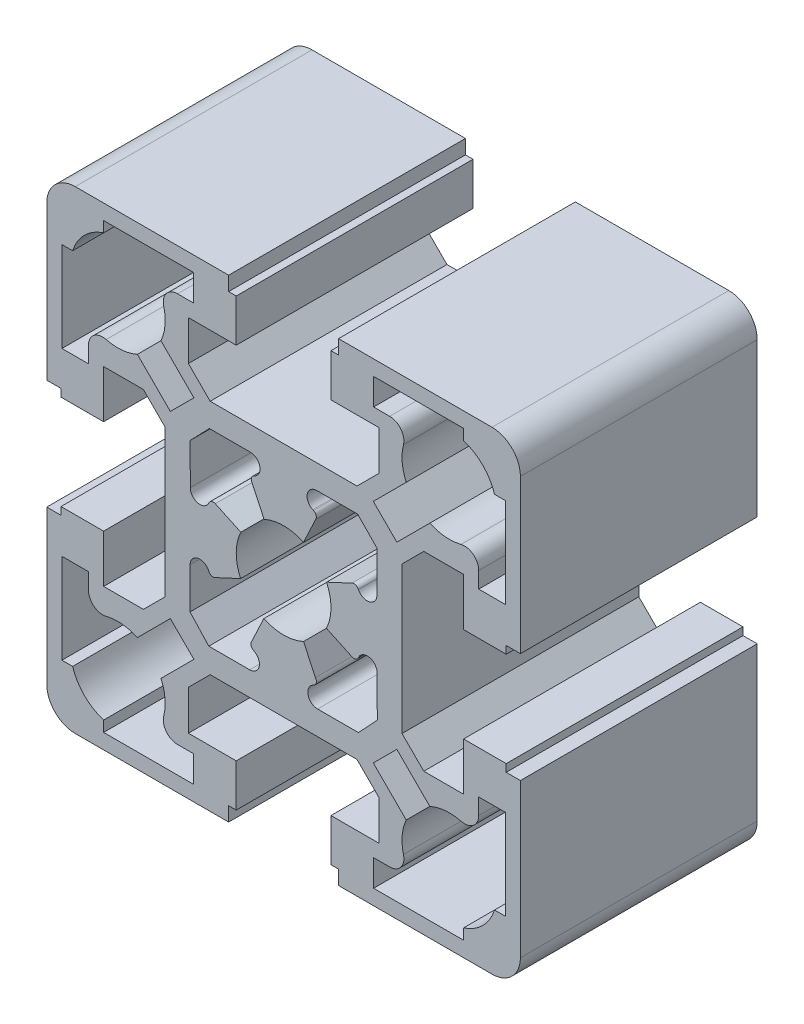
from build123d import *

# Parameters (mm, degrees)
BOSS_EXTRUDE1_DEPTH = 25


with BuildPart() as part:
    # Sketch1 → Boss-Extrude1 (new body)
    with BuildSketch(Plane.XY):
        with BuildLine():
            Line((5.619383592, -24.747070728), (21.819383592, -24.747070728))
            ThreePointArc((21.819383592, -24.747070728), (23.940703935, -23.868391071), (24.819383592, -21.747070728))
            Line((24.819383592, -21.747070728), (24.819383592, -5.547070728))
            Line((24.819383592, -5.547070728), (23.319383592, -5.547070728))
            Line((23.319383592, -5.547070728), (23.319383592, -4.747070728))
            Line((23.319383592, -4.747070728), (18.819383592, -4.747070728))
            Line((18.819383592, -4.747070728), (18.819383592, -9.797070728))
            Line((18.819383592, -9.797070728), (14.619383592, -9.797070728))
            Line((14.619383592, -9.797070728), (12.319383592, -7.497070728))
            Line((12.319383592, -7.497070728), (12.319383592, 8.002929272))
            Line((12.319383592, 8.002929272), (14.619383592, 10.302929272))
            Line((14.619383592, 10.302929272), (18.819383592, 10.302929272))
            Line((18.819383592, 10.302929272), (18.819383592, 5.252929272))
            Line((18.819383592, 5.252929272), (23.319383592, 5.252929272))
            Line((23.319383592, 5.252929272), (23.319383592, 6.052929272))
            Line((23.319383592, 6.052929272), (24.819383592, 6.052929272))
            Line((24.819383592, 6.052929272), (24.819383592, 22.252929272))
            ThreePointArc((24.819383592, 22.252929272), (23.940703935, 24.374249616), (21.819383592, 25.252929272))
            Line((21.819383592, 25.252929272), (5.619383592, 25.252929272))
            Line((5.619383592, 25.252929272), (5.619383592, 23.752929272))
            Line((5.619383592, 23.752929272), (4.819383592, 23.752929272))
            Line((4.819383592, 23.752929272), (4.819383592, 19.252929272))
            Line((4.819383592, 19.252929272), (9.869383592, 19.252929272))
            Line((9.869383592, 19.252929272), (9.869383592, 15.052929272))
            Line((9.869383592, 15.052929272), (7.569383592, 12.752929272))
            Line((7.569383592, 12.752929272), (-7.930616408, 12.752929272))
            Line((-7.930616408, 12.752929272), (-10.230616408, 15.052929272))
            Line((-10.230616408, 15.052929272), (-10.230616408, 19.252929272))
            Line((-10.230616408, 19.252929272), (-5.180616408, 19.252929272))
            Line((-5.180616408, 19.252929272), (-5.180616408, 23.752929272))
            Line((-5.180616408, 23.752929272), (-5.980616408, 23.752929272))
            Line((-5.980616408, 23.752929272), (-5.980616408, 25.252929272))
            Line((-5.980616408, 25.252929272), (-22.180616408, 25.252929272))
            ThreePointArc((-22.180616408, 25.252929272), (-24.301936752, 24.374249616), (-25.180616408, 22.252929272))
            Line((-25.180616408, 22.252929272), (-25.180616408, 6.052929272))
            Line((-25.180616408, 6.052929272), (-23.680616408, 6.052929272))
            Line((-23.680616408, 6.052929272), (-23.680616408, 5.252929272))
            Line((-23.680616408, 5.252929272), (-19.180616408, 5.252929272))
            Line((-19.180616408, 5.252929272), (-19.180616408, 10.302929272))
            Line((-19.180616408, 10.302929272), (-14.980616408, 10.302929272))
            Line((-14.980616408, 10.302929272), (-12.680616408, 8.002929272))
            Line((-12.680616408, 8.002929272), (-12.680616408, -7.497070728))
            Line((-12.680616408, -7.497070728), (-14.980616408, -9.797070728))
            Line((-14.980616408, -9.797070728), (-19.180616408, -9.797070728))
            Line((-19.180616408, -9.797070728), (-19.180616408, -4.747070728))
            Line((-19.180616408, -4.747070728), (-23.680616408, -4.747070728))
            Line((-23.680616408, -4.747070728), (-23.680616408, -5.547070728))
            Line((-23.680616408, -5.547070728), (-25.180616408, -5.547070728))
            Line((-25.180616408, -5.547070728), (-25.180616408, -21.747070728))
            ThreePointArc((-25.180616408, -21.747070728), (-24.301936752, -23.868391071), (-22.180616408, -24.747070728))
            Line((-22.180616408, -24.747070728), (-5.980616408, -24.747070728))
            Line((-5.980616408, -24.747070728), (-5.980616408, -23.247070728))
            Line((-5.980616408, -23.247070728), (-5.180616408, -23.247070728))
            Line((-5.180616408, -23.247070728), (-5.180616408, -18.747070728))
            Line((-5.180616408, -18.747070728), (-10.230616408, -18.747070728))
            Line((-10.230616408, -18.747070728), (-10.230616408, -14.547070728))
            Line((-10.230616408, -14.547070728), (-7.930616408, -12.247070728))
            Line((-7.930616408, -12.247070728), (7.569383592, -12.247070728))
            Line((7.569383592, -12.247070728), (9.869383592, -14.547070728))
            Line((9.869383592, -14.547070728), (9.869383592, -18.747070728))
            Line((9.869383592, -18.747070728), (4.819383592, -18.747070728))
            Line((4.819383592, -18.747070728), (4.819383592, -23.247070728))
            Line((4.819383592, -23.247070728), (5.619383592, -23.247070728))
            Line((5.619383592, -23.247070728), (5.619383592, -24.747070728))
        make_face()
        with BuildLine():
            Line((-19.180616408, 22.522625279), (-19.180616408, 23.652929272))
            Line((-19.180616408, 23.652929272), (-9.680616408, 23.652929272))
            Line((-9.680616408, 23.652929272), (-9.680616408, 20.852929272))
            Line((-9.680616408, 20.852929272), (-11.380454996, 20.852929272))
            ThreePointArc((-11.380454996, 20.852929272), (-12.564480507, 20.273843811), (-12.834303407, 18.98370739))
            ThreePointArc((-12.834303407, 18.98370739), (-12.700086931, 17.310333959), (-13.127278996, 15.686850161))
            Line((-13.127278996, 15.686850161), (-9.648762159, 12.208333323))
            Line((-9.648762159, 12.208333323), (-12.136020459, 9.721075023))
            Line((-12.136020459, 9.721075023), (-15.614537296, 13.19959186))
            ThreePointArc((-15.614537296, 13.19959186), (-17.238021094, 12.772399795), (-18.911394526, 12.906616271))
            ThreePointArc((-18.911394526, 12.906616271), (-20.201530947, 12.636793372), (-20.780616408, 11.45276786))
            Line((-20.780616408, 11.45276786), (-20.780616408, 9.752929272))
            Line((-20.780616408, 9.752929272), (-23.580616408, 9.752929272))
            Line((-23.580616408, 9.752929272), (-23.580616408, 19.252929272))
            Line((-23.580616408, 19.252929272), (-22.450312415, 19.252929272))
            ThreePointArc((-22.450312415, 19.252929272), (-21.216150314, 21.288463178), (-19.180616408, 22.522625279))
        make_face(mode=Mode.SUBTRACT)
        with BuildLine():
            Line((11.019222179, 20.852929272), (9.319383592, 20.852929272))
            Line((9.319383592, 20.852929272), (9.319383592, 23.652929272))
            Line((9.319383592, 23.652929272), (18.819383592, 23.652929272))
            Line((18.819383592, 23.652929272), (18.819383592, 22.522625279))
            ThreePointArc((18.819383592, 22.522625279), (20.854917498, 21.288463178), (22.089079599, 19.252929272))
            Line((22.089079599, 19.252929272), (23.219383592, 19.252929272))
            Line((23.219383592, 19.252929272), (23.219383592, 9.752929272))
            Line((23.219383592, 9.752929272), (20.419383592, 9.752929272))
            Line((20.419383592, 9.752929272), (20.419383592, 11.45276786))
            ThreePointArc((20.419383592, 11.45276786), (19.840298131, 12.636793372), (18.550161709, 12.906616271))
            ThreePointArc((18.550161709, 12.906616271), (16.876788278, 12.772399795), (15.25330448, 13.19959186))
            Line((15.25330448, 13.19959186), (11.774787642, 9.721075023))
            Line((11.774787642, 9.721075023), (9.287529342, 12.208333323))
            Line((9.287529342, 12.208333323), (12.76604618, 15.686850161))
            ThreePointArc((12.76604618, 15.686850161), (12.338854115, 17.310333959), (12.47307059, 18.98370739))
            ThreePointArc((12.47307059, 18.98370739), (12.203247691, 20.273843811), (11.019222179, 20.852929272))
        make_face(mode=Mode.SUBTRACT)
        with BuildLine():
            Line((18.819383592, -23.147070728), (9.319383592, -23.147070728))
            Line((9.319383592, -23.147070728), (9.319383592, -20.347070728))
            Line((9.319383592, -20.347070728), (11.019222179, -20.347070728))
            ThreePointArc((11.019222179, -20.347070728), (12.203247691, -19.767985267), (12.47307059, -18.477848845))
            ThreePointArc((12.47307059, -18.477848845), (12.338854115, -16.804475414), (12.76604618, -15.180991616))
            Line((12.76604618, -15.180991616), (9.287529342, -11.702474778))
            Line((9.287529342, -11.702474778), (11.774787642, -9.215216478))
            Line((11.774787642, -9.215216478), (15.25330448, -12.693733316))
            ThreePointArc((15.25330448, -12.693733316), (16.876788278, -12.266541251), (18.550161709, -12.400757726))
            ThreePointArc((18.550161709, -12.400757726), (19.840298131, -12.130934827), (20.419383592, -10.946909315))
            Line((20.419383592, -10.946909315), (20.419383592, -9.247070728))
            Line((20.419383592, -9.247070728), (23.219383592, -9.247070728))
            Line((23.219383592, -9.247070728), (23.219383592, -18.747070728))
            Line((23.219383592, -18.747070728), (22.089079599, -18.747070728))
            ThreePointArc((22.089079599, -18.747070728), (20.854917498, -20.782604634), (18.819383592, -22.016766735))
            Line((18.819383592, -22.016766735), (18.819383592, -23.147070728))
        make_face(mode=Mode.SUBTRACT)
        with BuildLine():
            Line((-12.136020459, -9.215216478), (-9.648762159, -11.702474778))
            Line((-9.648762159, -11.702474778), (-13.127278996, -15.180991616))
            ThreePointArc((-13.127278996, -15.180991616), (-12.700086931, -16.804475414), (-12.834303407, -18.477848845))
            ThreePointArc((-12.834303407, -18.477848845), (-12.564480507, -19.767985267), (-11.380454996, -20.347070728))
            Line((-11.380454996, -20.347070728), (-9.680616408, -20.347070728))
            Line((-9.680616408, -20.347070728), (-9.680616408, -23.147070728))
            Line((-9.680616408, -23.147070728), (-19.180616408, -23.147070728))
            Line((-19.180616408, -23.147070728), (-19.180616408, -22.016766735))
            ThreePointArc((-19.180616408, -22.016766735), (-21.216150314, -20.782604634), (-22.450312415, -18.747070728))
            Line((-22.450312415, -18.747070728), (-23.580616408, -18.747070728))
            Line((-23.580616408, -18.747070728), (-23.580616408, -9.247070728))
            Line((-23.580616408, -9.247070728), (-20.780616408, -9.247070728))
            Line((-20.780616408, -9.247070728), (-20.780616408, -10.946909315))
            ThreePointArc((-20.780616408, -10.946909315), (-20.201530947, -12.130934827), (-18.911394526, -12.400757726))
            ThreePointArc((-18.911394526, -12.400757726), (-17.238021094, -12.266541251), (-15.614537296, -12.693733316))
            Line((-15.614537296, -12.693733316), (-12.136020459, -9.215216478))
        make_face(mode=Mode.SUBTRACT)
        with BuildLine():
            Line((-4.696271643, 2.399754323), (-7.389166904, 3.655472006))
            ThreePointArc((-7.389166904, 3.655472006), (-7.771486106, 3.672164423), (-8.053629928, 3.413627243))
            Line((-8.053629928, 3.413627243), (-8.073343073, 3.371352269))
            ThreePointArc((-8.073343073, 3.371352269), (-9.225293311, 2.802514575), (-10.031035401, 3.803187028))
            Line((-10.031035401, 3.803187028), (-10.040182004, 8.120497908))
            Line((-10.040182004, 8.120497908), (-8.013775804, 10.218707242))
            Line((-8.013775804, 10.218707242), (-3.696455235, 10.218707242))
            ThreePointArc((-3.696455235, 10.218707242), (-2.694077997, 9.415086968), (-3.260473911, 8.261934185))
            Line((-3.260473911, 8.261934185), (-3.308123955, 8.239591582))
            ThreePointArc((-3.308123955, 8.239591582), (-3.579259283, 7.914638267), (-3.504066518, 7.498158891))
            Line((-3.504066518, 7.498158891), (-2.242646531, 4.807930016))
            ThreePointArc((-2.242646531, 4.807930016), (-0.154465158, 5.252860883), (1.928947832, 4.786111236))
            Line((1.928947832, 4.786111236), (3.184665515, 7.479006497))
            ThreePointArc((3.184665515, 7.479006497), (3.255385218, 7.894494419), (2.983380008, 8.21643332))
            Line((2.983380008, 8.21643332), (2.892369377, 8.258637766))
            ThreePointArc((2.892369377, 8.258637766), (2.32113411, 9.412363276), (3.324728495, 10.218707242))
            Line((3.324728495, 10.218707242), (7.642049064, 10.218707242))
            Line((7.642049064, 10.218707242), (9.678970812, 8.130704777))
            Line((9.678970812, 8.130704777), (9.669824208, 3.813393897))
            ThreePointArc((9.669824208, 3.813393897), (8.871021226, 2.812095794), (7.714930135, 3.363582409))
            ThreePointArc((7.714930135, 3.363582409), (7.434168717, 3.629452931), (7.047786525, 3.614522776))
            Line((7.047786525, 3.614522776), (4.355242204, 2.356732173))
            ThreePointArc((4.355242204, 2.356732173), (4.819370654, 0.241554795), (4.345623418, -1.871489009))
            Line((4.345623418, -1.871489009), (7.041172978, -3.12149875))
            ThreePointArc((7.041172978, -3.12149875), (7.423526687, -3.137381155), (7.705122143, -2.87824681))
            Line((7.705122143, -2.87824681), (7.726414155, -2.83233223))
            ThreePointArc((7.726414155, -2.83233223), (8.881491342, -2.258903401), (9.692394713, -3.261629512))
            Line((9.692394713, -3.261629512), (9.710687879, -7.578911325))
            Line((9.710687879, -7.578911325), (7.721940588, -9.712848697))
            Line((7.721940588, -9.712848697), (3.404620018, -9.712848697))
            ThreePointArc((3.404620018, -9.712848697), (2.398177111, -8.905092866), (2.96895179, -7.747676314))
            Line((2.96895179, -7.747676314), (3.000911142, -7.732773423))
            ThreePointArc((3.000911142, -7.732773423), (3.275585197, -7.397179484), (3.184665515, -6.973147952))
            Line((3.184665515, -6.973147952), (1.928947832, -4.280252691))
            ThreePointArc((1.928947832, -4.280252691), (-0.170199387, -4.747059876), (-2.271273475, -4.289003469))
            Line((-2.271273475, -4.289003469), (-3.532693462, -6.979232344))
            ThreePointArc((-3.532693462, -6.979232344), (-3.627832058, -7.404426214), (-3.353347097, -7.742803497))
            Line((-3.353347097, -7.742803497), (-3.325041612, -7.756075641))
            ThreePointArc((-3.325041612, -7.756075641), (-2.758645698, -8.909228424), (-3.761022936, -9.712848697))
            Line((-3.761022936, -9.712848697), (-8.078343505, -9.712848697))
            Line((-8.078343505, -9.712848697), (-10.060166007, -7.57247862))
            Line((-10.060166007, -7.57247862), (-10.051019404, -3.255167739))
            ThreePointArc((-10.051019404, -3.255167739), (-9.245210095, -2.254411806), (-8.093163755, -2.823296955))
            Line((-8.093163755, -2.823296955), (-8.073405042, -2.865669653))
            ThreePointArc((-8.073405042, -2.865669653), (-7.79126122, -3.124206832), (-7.408942017, -3.107514415))
            Line((-7.408942017, -3.107514415), (-4.716046757, -1.851796733))
            ThreePointArc((-4.716046757, -1.851796733), (-5.180562323, 0.276185373), (-4.696271643, 2.399754323))
        make_face(mode=Mode.SUBTRACT)
    extrude(amount=BOSS_EXTRUDE1_DEPTH)


solid = part.part
